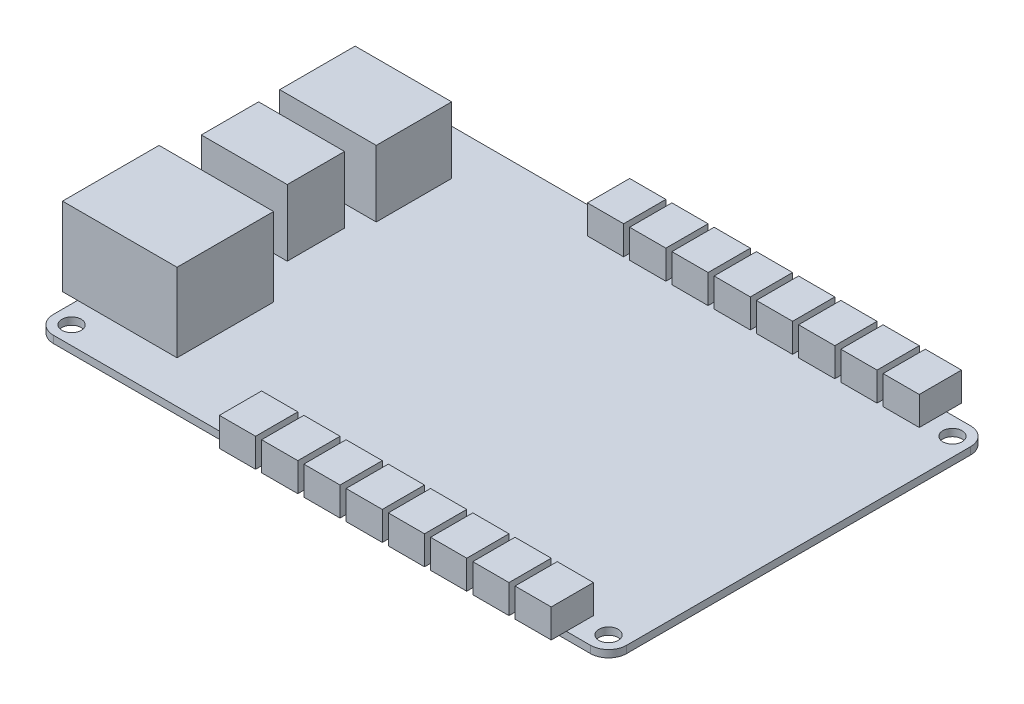
from build123d import *

# Parameters (mm, degrees)
SKETCH1_R            = 1.6
PCB_DEPTH            = 1.2
SKETCH2_W            = 6
SKETCH2_H            = 7
POP_CONNECTORS_DEPTH = 4.75
USB_W                = 16
USB_H                = 12.5
USB_B_DEPTH          = 11
SKETCH4_W            = 14.25
SKETCH4_H            = 9.5
DC_POWER_DEPTH       = 11
SKETCH5_W            = 18.982296278
SKETCH5_H            = 16
RJ45_DEPTH           = 13


with BuildPart() as part:
    # Sketch1 → pcb (new body)
    with BuildSketch(Plane(origin=(0, 0, 0), x_dir=(1, 0, 0), z_dir=(0, 1, 0))):
        with BuildLine():
            Line((-54.767524261, 6.744107228), (34.232475739, 6.744107228))
            ThreePointArc((34.232475739, 6.744107228), (36.353796082, 5.865427572), (37.232475739, 3.744107228))
            Line((37.232475739, 3.744107228), (37.232475739, -53.255892772))
            ThreePointArc((37.232475739, -53.255892772), (36.353796082, -55.377213115), (34.232475739, -56.255892772))
            Line((34.232475739, -56.255892772), (-54.767524261, -56.255892772))
            ThreePointArc((-54.767524261, -56.255892772), (-56.888844605, -55.377213115), (-57.767524261, -53.255892772))
            Line((-57.767524261, -53.255892772), (-57.767524261, 3.744107228))
            ThreePointArc((-57.767524261, 3.744107228), (-56.888844605, 5.865427572), (-54.767524261, 6.744107228))
        make_face()
        with Locations((-54.767524261, 3.744107228)):
            Circle(SKETCH1_R, mode=Mode.SUBTRACT)
        with Locations((-54.767524261, -53.255892772)):
            Circle(SKETCH1_R, mode=Mode.SUBTRACT)
        with Locations((34.232475739, -53.255892772)):
            Circle(SKETCH1_R, mode=Mode.SUBTRACT)
        with Locations((34.232475739, 3.744107228)):
            Circle(SKETCH1_R, mode=Mode.SUBTRACT)
    extrude(amount=PCB_DEPTH)

    # Sketch2 → pop connectors (add)
    with BuildSketch(Plane(origin=(0, 1.2, 0), x_dir=(1, 0, 0), z_dir=(0, 1, 0))):
        with Locations((-14.767524261, -55.255892772)):
            Rectangle(SKETCH2_W, SKETCH2_H)
        with Locations((-21.767524261, -55.255892772)):
            Rectangle(SKETCH2_W, SKETCH2_H)
        with Locations((-7.767524261, -55.255892772)):
            Rectangle(SKETCH2_W, SKETCH2_H)
        with Locations((-0.767524261, -55.255892772)):
            Rectangle(SKETCH2_W, SKETCH2_H)
        with Locations((6.232475739, -55.255892772)):
            Rectangle(SKETCH2_W, SKETCH2_H)
        with Locations((13.232475739, -55.255892772)):
            Rectangle(SKETCH2_W, SKETCH2_H)
        with Locations((20.232475739, -55.255892772)):
            Rectangle(SKETCH2_W, SKETCH2_H)
        with Locations((27.232475739, -55.255892772)):
            Rectangle(SKETCH2_W, SKETCH2_H)
        with Locations((27.232475739, 5.744107228)):
            Rectangle(SKETCH2_W, SKETCH2_H)
        with Locations((20.232475739, 5.744107228)):
            Rectangle(SKETCH2_W, SKETCH2_H)
        with Locations((13.232475739, 5.744107228)):
            Rectangle(SKETCH2_W, SKETCH2_H)
        with Locations((6.232475739, 5.744107228)):
            Rectangle(SKETCH2_W, SKETCH2_H)
        with Locations((-0.767524261, 5.744107228)):
            Rectangle(SKETCH2_W, SKETCH2_H)
        with Locations((-7.767524261, 5.744107228)):
            Rectangle(SKETCH2_W, SKETCH2_H)
        with Locations((-14.767524261, 5.744107228)):
            Rectangle(SKETCH2_W, SKETCH2_H)
        with Locations((-21.767524261, 5.744107228)):
            Rectangle(SKETCH2_W, SKETCH2_H)
    extrude(amount=POP_CONNECTORS_DEPTH)

    # usb → USB B (add)
    with BuildSketch(Plane(origin=(0, 1.2, 0), x_dir=(1, 0, 0), z_dir=(0, 1, 0))):
        with Locations((-52.267524261, -7.005892772)):
            Rectangle(USB_W, USB_H)
    extrude(amount=USB_B_DEPTH)

    # Sketch4 → DC power (add)
    with BuildSketch(Plane(origin=(0, 1.2, 0), x_dir=(1, 0, 0), z_dir=(0, 1, 0))):
        with Locations((-53.142524261, -21.505892772)):
            Rectangle(SKETCH4_W, SKETCH4_H)
    extrude(amount=DC_POWER_DEPTH)

    # Sketch5 → RJ45 (add)
    with BuildSketch(Plane(origin=(0, 1.2, 0), x_dir=(1, 0, 0), z_dir=(0, 1, 0))):
        with Locations((-50.776376122, -41.255892772)):
            Rectangle(SKETCH5_W, SKETCH5_H)
    extrude(amount=RJ45_DEPTH)


solid = part.part
